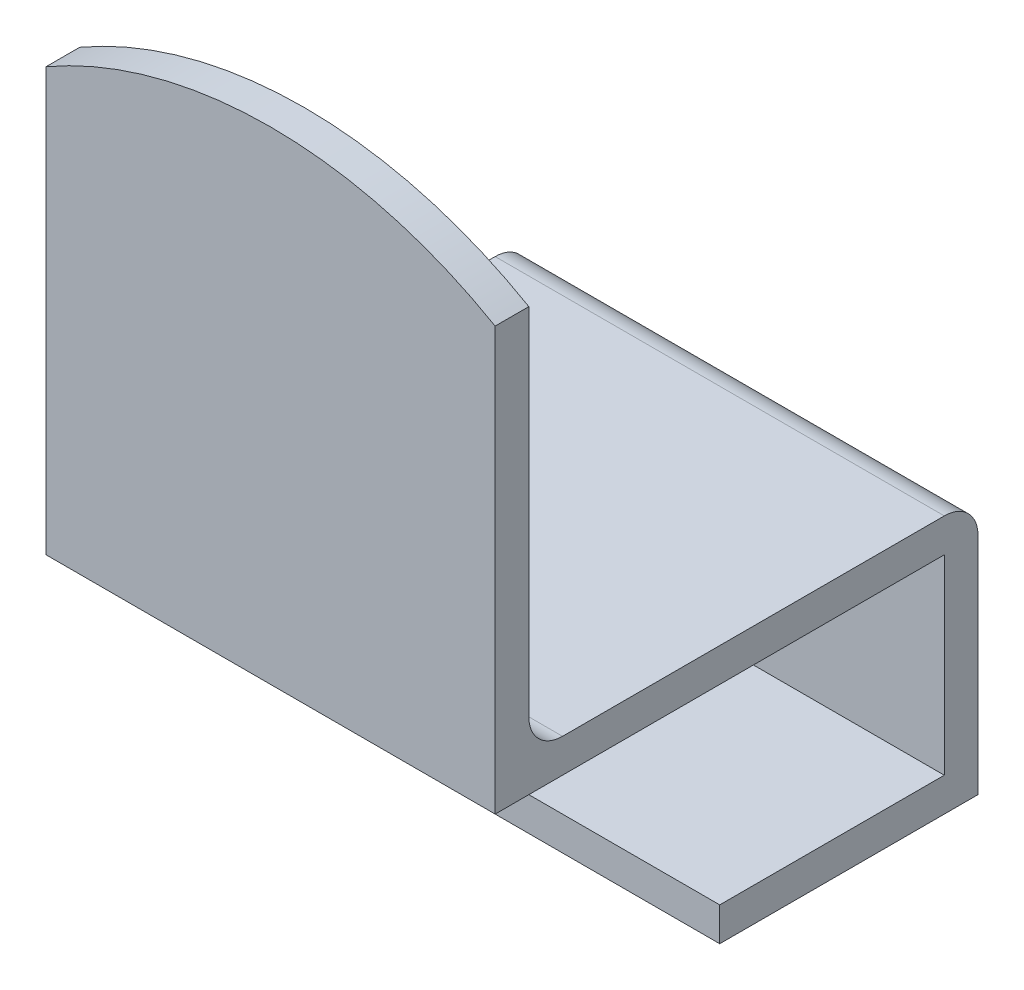
from build123d import *

# Parameters (mm, degrees)
SKETCH1_W           = 40
SKETCH1_H           = 40
BOSS_EXTRUDE1_DEPTH = 3
SKETCH2_W           = 40
SKETCH2_H           = 3
BOSS_EXTRUDE2_DEPTH = 53
SKETCH3_W           = 40
SKETCH3_H           = 3
BOSS_EXTRUDE3_DEPTH = 20
CUT_EXTRUDE1_REACH  = 5
FILLET1_R           = 3
SKETCH5_W           = 40
SKETCH5_H           = 3
BOSS_EXTRUDE4_DEPTH = 20


with BuildPart() as part:
    # Sketch1 → Boss-Extrude1 (new body)
    with BuildSketch(Plane(origin=(0, 0, 0), x_dir=(1, 0, 0), z_dir=(0, 1, 0))):
        Rectangle(SKETCH1_W, SKETCH1_H)
    extrude(amount=BOSS_EXTRUDE1_DEPTH)

    # Sketch2 → Boss-Extrude2 (add)
    with BuildSketch(Plane(origin=(0, 0, 0), x_dir=(1, 0, 0), z_dir=(0, 1, 0))):
        with Locations((0, -21.5)):
            Rectangle(SKETCH2_W, SKETCH2_H)
    extrude(amount=BOSS_EXTRUDE2_DEPTH)

    # Sketch3 → Boss-Extrude3 (add)
    with BuildSketch(Plane.XZ):
        with Locations((0, -18.5)):
            Rectangle(SKETCH3_W, SKETCH3_H)
    extrude(amount=BOSS_EXTRUDE3_DEPTH)

    # Sketch4 → Cut-Extrude1 (cut, up to next)
    with BuildSketch(Plane(origin=(0, 0, 20), x_dir=(-1, 0, 0), z_dir=(0, 0, -1)), mode=Mode.PRIVATE) as cut_extrude1_sk1:
        with BuildLine():
            Line((-20, 37.641016151), (-20, 53))
            Line((-20, 53), (20, 53))
            Line((20, 53), (20, 37.641016151))
            ThreePointArc((20, 37.641016151), (0, 43), (-20, 37.641016151))
        make_face()
    cut_extrude1_tool1 = extrude(cut_extrude1_sk1.sketch, amount=-CUT_EXTRUDE1_REACH, mode=Mode.PRIVATE) & part.part
    add(cut_extrude1_tool1.solids().sort_by_distance((0, 47.025808, 20))[0], mode=Mode.SUBTRACT)

    # Fillet1
    fillet1_edges = [part.edges().sort_by_distance(p)[0] for p in [
        (0, 3, 20),
        (0, 3, -20),
    ]]
    fillet(fillet1_edges, radius=FILLET1_R)

    # Sketch5 → Boss-Extrude4 (add)
    with BuildSketch(Plane.XY.offset(-17)):
        with Locations((0, -18.5)):
            Rectangle(SKETCH5_W, SKETCH5_H)
    extrude(amount=BOSS_EXTRUDE4_DEPTH)


solid = part.part
